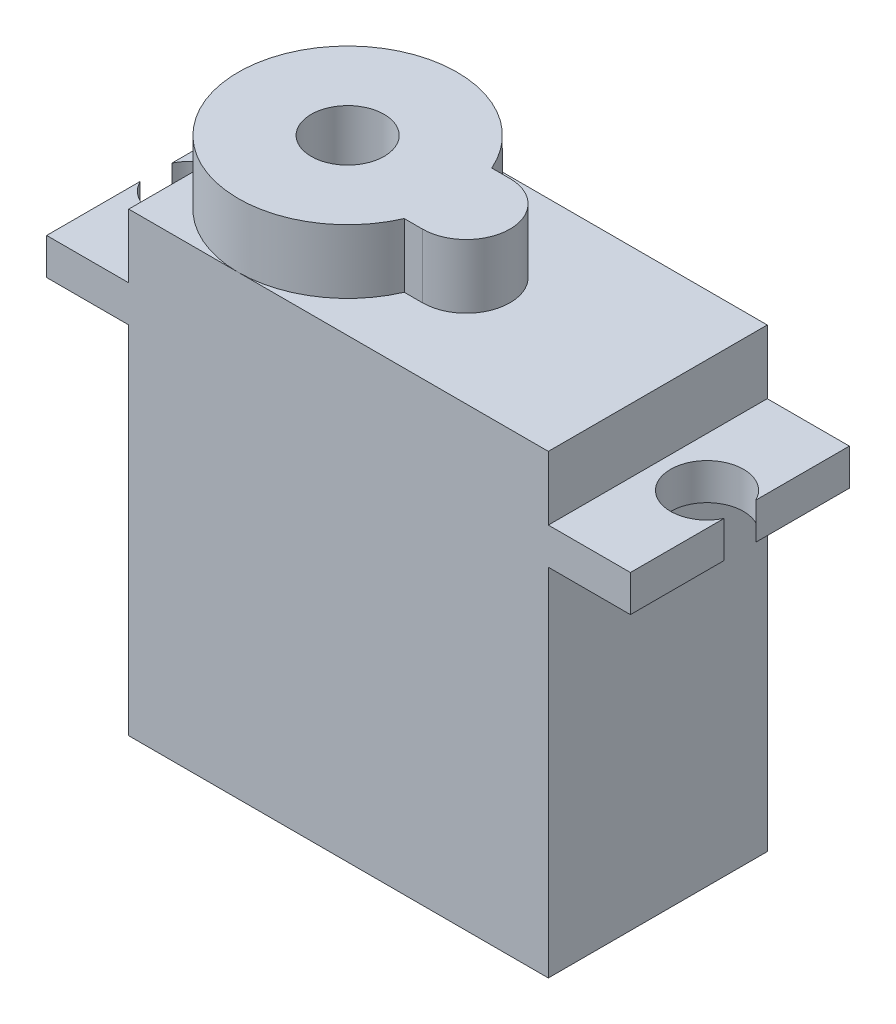
from build123d import *

# Parameters (mm, degrees)
SKETCH1_R           = 6
SKETCH1_R_2         = 2
BOSS_EXTRUDE1_DEPTH = 25
BOSS_EXTRUDE2_START = 19.5
BOSS_EXTRUDE2_DEPTH = 2
BOSS_EXTRUDE3_START = 25
SKETCH1_6_R         = 6
SKETCH1_6_R_2       = 2
BOSS_EXTRUDE3_DEPTH = 3.5
SKETCH1_7_R         = 2
BOSS_EXTRUDE4_DEPTH = 5


with BuildPart() as part:
    # Sketch1 → Boss-Extrude1 (new body)
    with BuildSketch(Plane(origin=(0, 0, 0), x_dir=(1, 0, 0), z_dir=(0, 1, 0))):
        with Locations((-5.5, 0)):
            Circle(SKETCH1_R)
        with Locations(Location((-5.5, 0, 0), (0, 0, 270))):
            Circle(SKETCH1_R_2, mode=Mode.SUBTRACT)
        with BuildLine():
            ThreePointArc((-5.499999996, 6), (-2.212713471, 5.019337334), (0, 2.397915762))
            Line((0, 2.397915762), (1, 2.397915762))
            ThreePointArc((1, 2.397915762), (3.397915762, 0), (1, -2.397915762))
            Line((1, -2.397915762), (0, -2.397915762))
            ThreePointArc((0, -2.397915762), (-2.212713472, -5.019337335), (-5.5, -6))
            Line((-5.5, -6), (11.5, -6))
            Line((11.5, -6), (11.5, 6))
            Line((11.5, 6), (-5.499999996, 6))
        make_face()
        with BuildLine():
            ThreePointArc((-5.5, -6), (-9.742640687, -4.242640687), (-11.5, 0))
            Line((-11.5, 0), (-11.5, -6))
            Line((-11.5, -6), (-5.5, -6))
        make_face()
        with BuildLine():
            Line((1, 2.397915762), (0, 2.397915762))
            ThreePointArc((0, 2.397915762), (0.373670062, 1.224744871), (0.5, 0))
            ThreePointArc((0.5, 0), (0.373670062, -1.224744871), (0, -2.397915762))
            Line((0, -2.397915762), (1, -2.397915762))
            ThreePointArc((1, -2.397915762), (3.397915762, 0), (1, 2.397915762))
        make_face()
        with BuildLine():
            ThreePointArc((-11.5, 0), (-9.742640686, 4.242640689), (-5.499999996, 6))
            Line((-5.499999996, 6), (-11.5, 6))
            Line((-11.5, 6), (-11.5, 0))
        make_face()
    extrude(amount=BOSS_EXTRUDE1_DEPTH)

    # Sketch1_4 → Boss-Extrude2 (add)
    with BuildSketch(Plane(origin=(0, 0, 0), x_dir=(1, 0, 0), z_dir=(0, 1, 0)).offset(BOSS_EXTRUDE2_START)):
        with BuildLine():
            Line((16, 6), (11.5, 6))
            Line((11.5, 6), (11.5, -6))
            Line((11.5, -6), (16, -6))
            Line((16, -6), (16, -0.871779789))
            ThreePointArc((16, -0.871779789), (12.2, 0), (16, 0.871779789))
            Line((16, 0.871779789), (16, 6))
        make_face()
        with BuildLine():
            Line((-11.5, 0), (-11.5, 6))
            Line((-11.5, 6), (-16, 6))
            Line((-16, 6), (-16, 0.871779789))
            ThreePointArc((-16, 0.871779789), (-13.752786405, 1.949358869), (-12.2, 0))
            ThreePointArc((-12.2, 0), (-13.752786405, -1.949358869), (-16, -0.871779789))
            Line((-16, -0.871779789), (-16, -6))
            Line((-16, -6), (-11.5, -6))
            Line((-11.5, -6), (-11.5, 0))
        make_face()
    extrude(amount=BOSS_EXTRUDE2_DEPTH)

    # Sketch1_6 → Boss-Extrude3 (add)
    with BuildSketch(Plane(origin=(0, 0, 0), x_dir=(1, 0, 0), z_dir=(0, 1, 0)).offset(BOSS_EXTRUDE3_START)):
        with Locations((-5.5, 0)):
            Circle(SKETCH1_6_R)
        with Locations(Location((-5.5, 0, 0), (0, 0, 270))):
            Circle(SKETCH1_6_R_2, mode=Mode.SUBTRACT)
        with BuildLine():
            Line((1, 2.397915762), (0, 2.397915762))
            ThreePointArc((0, 2.397915762), (0.373670062, 1.224744871), (0.5, 0))
            ThreePointArc((0.5, 0), (0.373670062, -1.224744871), (0, -2.397915762))
            Line((0, -2.397915762), (1, -2.397915762))
            ThreePointArc((1, -2.397915762), (3.397915762, 0), (1, 2.397915762))
        make_face()
    extrude(amount=BOSS_EXTRUDE3_DEPTH)

    # Sketch1_7 → Boss-Extrude4 (add)
    with BuildSketch(Plane(origin=(0, 0, 0), x_dir=(1, 0, 0), z_dir=(0, 1, 0))):
        with Locations(Location((-5.5, 0, 0), (0, 0, 270))):
            Circle(SKETCH1_7_R)
    extrude(amount=BOSS_EXTRUDE4_DEPTH)


solid = part.part
